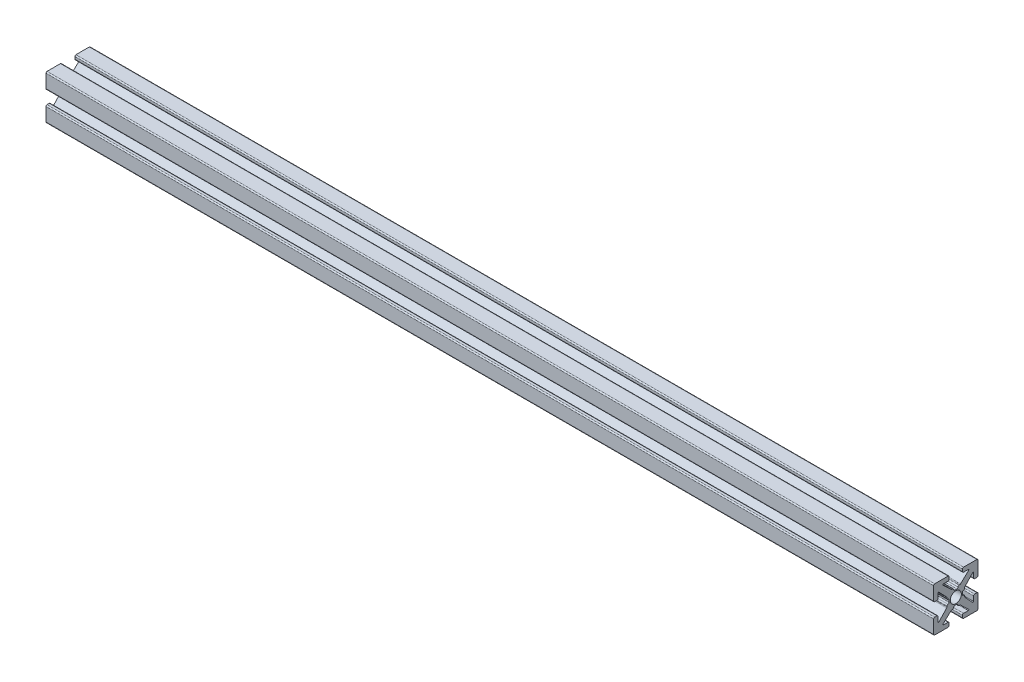
from build123d import *

# Parameters (mm, degrees)
ESTRUSIONE_ESTRUSIONE1_DEPTH = 200
FORO_FILETTATO_M3X0_5_1_D    = 2.5


with BuildPart() as part:
    # Sketch1 → Estrusione-Estrusione1 (new body)
    with BuildSketch(Plane(origin=(0, 0, 0), x_dir=(0, 0, -1), z_dir=(1, 0, 0))):
        with BuildLine():
            Line((-0.2413, 1.4948), (0.2413, 1.4948))
            ThreePointArc((0.2413, 1.4948), (0.420905122, 1.569194878), (0.4953, 1.7488))
            ThreePointArc((0.4953, 1.7488), (0.569694878, 1.928405122), (0.7493, 2.0028))
            Line((0.7493, 2.0028), (0.889923986, 2.0028))
            ThreePointArc((0.889923986, 2.0028), (0.983516259, 2.020671886), (1.063937899, 2.071772548))
            Line((1.063937899, 2.071772548), (2.890793, 3.789886274))
            ThreePointArc((2.890793, 3.789886274), (2.921850101, 3.929196137), (2.803786044, 4.0094))
            Line((2.803786044, 4.0094), (1.7526, 4.0094))
            ThreePointArc((1.7526, 4.0094), (1.572994878, 4.083794878), (1.4986, 4.2634))
            Line((1.4986, 4.2634), (1.4986, 4.746))
            ThreePointArc((1.4986, 4.746), (1.572994878, 4.925605122), (1.7526, 5))
            Line((1.7526, 5), (4.746, 5))
            ThreePointArc((4.746, 5), (4.925605122, 4.925605122), (5, 4.746))
            Line((5, 4.746), (5, 1.7526))
            ThreePointArc((5, 1.7526), (4.925605122, 1.572994878), (4.746, 1.4986))
            Line((4.746, 1.4986), (4.2634, 1.4986))
            ThreePointArc((4.2634, 1.4986), (4.083794878, 1.572994878), (4.0094, 1.7526))
            Line((4.0094, 1.7526), (4.0094, 2.803786044))
            ThreePointArc((4.0094, 2.803786044), (3.929196137, 2.921850101), (3.789886274, 2.890793))
            Line((3.789886274, 2.890793), (2.071772548, 1.063937899))
            ThreePointArc((2.071772548, 1.063937899), (2.020671886, 0.983516259), (2.0028, 0.889923986))
            Line((2.0028, 0.889923986), (2.0028, 0.7493))
            ThreePointArc((2.0028, 0.7493), (1.928405122, 0.569694878), (1.7488, 0.4953))
            ThreePointArc((1.7488, 0.4953), (1.569194878, 0.420905122), (1.4948, 0.2413))
            Line((1.4948, 0.2413), (1.4948, -0.2413))
            ThreePointArc((1.4948, -0.2413), (1.569194878, -0.420905122), (1.7488, -0.4953))
            ThreePointArc((1.7488, -0.4953), (1.928405122, -0.569694878), (2.0028, -0.7493))
            Line((2.0028, -0.7493), (2.0028, -0.889923986))
            ThreePointArc((2.0028, -0.889923986), (2.020671886, -0.983516259), (2.071772548, -1.063937899))
            Line((2.071772548, -1.063937899), (3.789886274, -2.890793))
            ThreePointArc((3.789886274, -2.890793), (3.929196137, -2.921850101), (4.0094, -2.803786044))
            Line((4.0094, -2.803786044), (4.0094, -1.7526))
            ThreePointArc((4.0094, -1.7526), (4.083794878, -1.572994878), (4.2634, -1.4986))
            Line((4.2634, -1.4986), (4.746, -1.4986))
            ThreePointArc((4.746, -1.4986), (4.925605122, -1.572994878), (5, -1.7526))
            Line((5, -1.7526), (5, -4.746))
            ThreePointArc((5, -4.746), (4.925605122, -4.925605122), (4.746, -5))
            Line((4.746, -5), (1.7526, -5))
            ThreePointArc((1.7526, -5), (1.572994878, -4.925605122), (1.4986, -4.746))
            Line((1.4986, -4.746), (1.4986, -4.2634))
            ThreePointArc((1.4986, -4.2634), (1.572994878, -4.083794878), (1.7526, -4.0094))
            Line((1.7526, -4.0094), (2.803786044, -4.0094))
            ThreePointArc((2.803786044, -4.0094), (2.921850101, -3.929196137), (2.890793, -3.789886274))
            Line((2.890793, -3.789886274), (1.063937899, -2.071772548))
            ThreePointArc((1.063937899, -2.071772548), (0.983516259, -2.020671886), (0.889923986, -2.0028))
            Line((0.889923986, -2.0028), (0.7493, -2.0028))
            ThreePointArc((0.7493, -2.0028), (0.569694878, -1.928405122), (0.4953, -1.7488))
            ThreePointArc((0.4953, -1.7488), (0.420905122, -1.569194878), (0.2413, -1.4948))
            Line((0.2413, -1.4948), (-0.2413, -1.4948))
            ThreePointArc((-0.2413, -1.4948), (-0.420905122, -1.569194878), (-0.4953, -1.7488))
            ThreePointArc((-0.4953, -1.7488), (-0.569694878, -1.928405122), (-0.7493, -2.0028))
            Line((-0.7493, -2.0028), (-0.889923986, -2.0028))
            ThreePointArc((-0.889923986, -2.0028), (-0.983516259, -2.020671886), (-1.063937899, -2.071772548))
            Line((-1.063937899, -2.071772548), (-2.890793, -3.789886274))
            ThreePointArc((-2.890793, -3.789886274), (-2.921850101, -3.929196137), (-2.803786044, -4.0094))
            Line((-2.803786044, -4.0094), (-1.7526, -4.0094))
            ThreePointArc((-1.7526, -4.0094), (-1.572994878, -4.083794878), (-1.4986, -4.2634))
            Line((-1.4986, -4.2634), (-1.4986, -4.746))
            ThreePointArc((-1.4986, -4.746), (-1.572994878, -4.925605122), (-1.7526, -5))
            Line((-1.7526, -5), (-4.746, -5))
            ThreePointArc((-4.746, -5), (-4.925605122, -4.925605122), (-5, -4.746))
            Line((-5, -4.746), (-5, -1.7526))
            ThreePointArc((-5, -1.7526), (-4.925605122, -1.572994878), (-4.746, -1.4986))
            Line((-4.746, -1.4986), (-4.2634, -1.4986))
            ThreePointArc((-4.2634, -1.4986), (-4.083794878, -1.572994878), (-4.0094, -1.7526))
            Line((-4.0094, -1.7526), (-4.0094, -2.803786044))
            ThreePointArc((-4.0094, -2.803786044), (-3.929196137, -2.921850101), (-3.789886274, -2.890793))
            Line((-3.789886274, -2.890793), (-2.071772548, -1.063937899))
            ThreePointArc((-2.071772548, -1.063937899), (-2.020671886, -0.983516259), (-2.0028, -0.889923986))
            Line((-2.0028, -0.889923986), (-2.0028, -0.7493))
            ThreePointArc((-2.0028, -0.7493), (-1.928405122, -0.569694878), (-1.7488, -0.4953))
            ThreePointArc((-1.7488, -0.4953), (-1.569194878, -0.420905122), (-1.4948, -0.2413))
            Line((-1.4948, -0.2413), (-1.4948, 0.2413))
            ThreePointArc((-1.4948, 0.2413), (-1.569194878, 0.420905122), (-1.7488, 0.4953))
            ThreePointArc((-1.7488, 0.4953), (-1.928405122, 0.569694878), (-2.0028, 0.7493))
            Line((-2.0028, 0.7493), (-2.0028, 0.889923986))
            ThreePointArc((-2.0028, 0.889923986), (-2.020671886, 0.983516259), (-2.071772548, 1.063937899))
            Line((-2.071772548, 1.063937899), (-3.789886274, 2.890793))
            ThreePointArc((-3.789886274, 2.890793), (-3.929196137, 2.921850101), (-4.0094, 2.803786044))
            Line((-4.0094, 2.803786044), (-4.0094, 1.7526))
            ThreePointArc((-4.0094, 1.7526), (-4.083794878, 1.572994878), (-4.2634, 1.4986))
            Line((-4.2634, 1.4986), (-4.746, 1.4986))
            ThreePointArc((-4.746, 1.4986), (-4.925605122, 1.572994878), (-5, 1.7526))
            Line((-5, 1.7526), (-5, 4.746))
            ThreePointArc((-5, 4.746), (-4.925605122, 4.925605122), (-4.746, 5))
            Line((-4.746, 5), (-1.7526, 5))
            ThreePointArc((-1.7526, 5), (-1.572994878, 4.925605122), (-1.4986, 4.746))
            Line((-1.4986, 4.746), (-1.4986, 4.2634))
            ThreePointArc((-1.4986, 4.2634), (-1.572994878, 4.083794878), (-1.7526, 4.0094))
            Line((-1.7526, 4.0094), (-2.803786044, 4.0094))
            ThreePointArc((-2.803786044, 4.0094), (-2.921850101, 3.929196137), (-2.890793, 3.789886274))
            Line((-2.890793, 3.789886274), (-1.063937899, 2.071772548))
            ThreePointArc((-1.063937899, 2.071772548), (-0.983516259, 2.020671886), (-0.889923986, 2.0028))
            Line((-0.889923986, 2.0028), (-0.7493, 2.0028))
            ThreePointArc((-0.7493, 2.0028), (-0.569694878, 1.928405122), (-0.4953, 1.7488))
            ThreePointArc((-0.4953, 1.7488), (-0.420905122, 1.569194878), (-0.2413, 1.4948))
        make_face()
    extrude(amount=ESTRUSIONE_ESTRUSIONE1_DEPTH)

    # Foro filettato M3x0.5-1 (through all)
    with Locations(Plane.ZY):
        with Locations((0, 0)):
            Hole(FORO_FILETTATO_M3X0_5_1_D / 2)


solid = part.part
